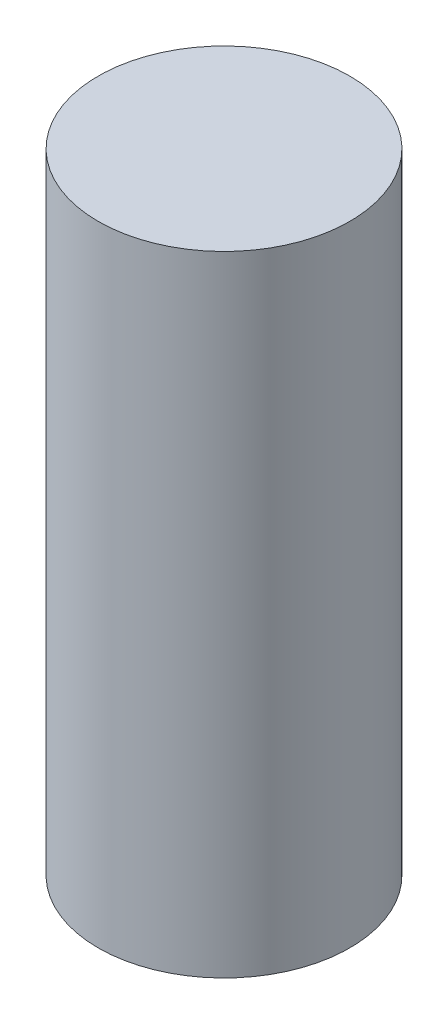
from build123d import *

# Parameters (mm, degrees)
SKETCH1_R  = 2
BASE_DEPTH = 10


with BuildPart() as part:
    # Sketch1 → base (new body)
    with BuildSketch(Plane(origin=(0, 0, 0), x_dir=(1, 0, 0), z_dir=(0, 1, 0))):
        Circle(SKETCH1_R)
    extrude(amount=BASE_DEPTH)


solid = part.part
